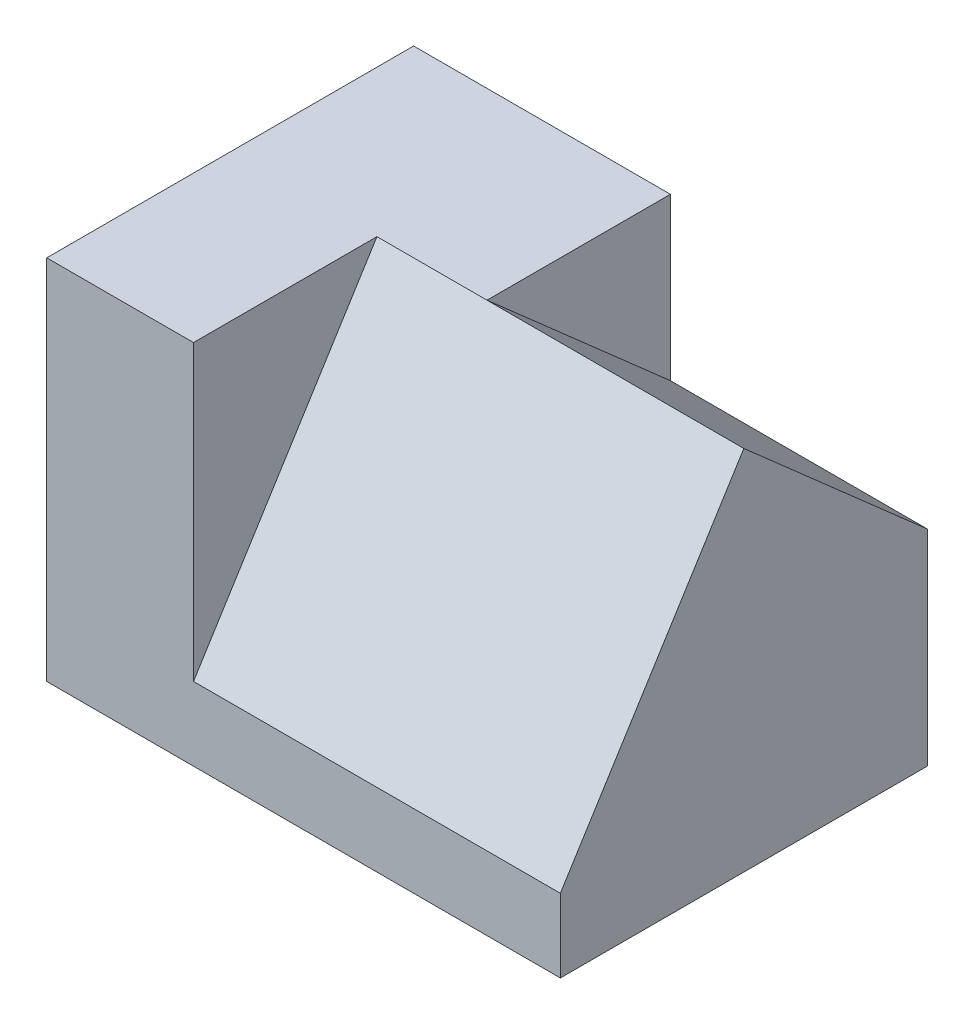
from build123d import *

# Parameters (mm, degrees)
SKETCH1_W               = 700
SKETCH1_H               = 500
BOSS_EXTRUDE1_DEPTH     = 500
CUT_EXTRUDE1_DEPTH      = 1
CUT_EXTRUDE1_DEPTH_BACK = 500
CUT_EXTRUDE2_DEPTH      = 1
CUT_EXTRUDE2_DEPTH_BACK = 350


with BuildPart() as part:
    # Sketch1 → Boss-Extrude1 (new body)
    with BuildSketch(Plane(origin=(0, 0, 0), x_dir=(1, 0, 0), z_dir=(0, 1, 0))):
        with Locations((350, 250)):
            Rectangle(SKETCH1_W, SKETCH1_H)
    extrude(amount=BOSS_EXTRUDE1_DEPTH)

    # Sketch3 → Cut-Extrude1 (cut, two sides)
    with BuildSketch(Plane(origin=(700, 0, 0), x_dir=(0, 0, -1), z_dir=(1, 0, 0))) as cut_extrude1_sk:
        Polygon((0, 100), (250, 500), (0, 500), align=None)
    extrude(amount=CUT_EXTRUDE1_DEPTH, mode=Mode.SUBTRACT)
    extrude(cut_extrude1_sk.sketch, amount=-CUT_EXTRUDE1_DEPTH_BACK, mode=Mode.SUBTRACT)

    # Sketch3_3 → Cut-Extrude2 (cut, two sides)
    with BuildSketch(Plane(origin=(700, 0, 0), x_dir=(0, 0, -1), z_dir=(1, 0, 0))) as cut_extrude2_sk:
        Polygon((500, 500), (250, 500), (500, 280), align=None)
    extrude(amount=CUT_EXTRUDE2_DEPTH, mode=Mode.SUBTRACT)
    extrude(cut_extrude2_sk.sketch, amount=-CUT_EXTRUDE2_DEPTH_BACK, mode=Mode.SUBTRACT)


solid = part.part
